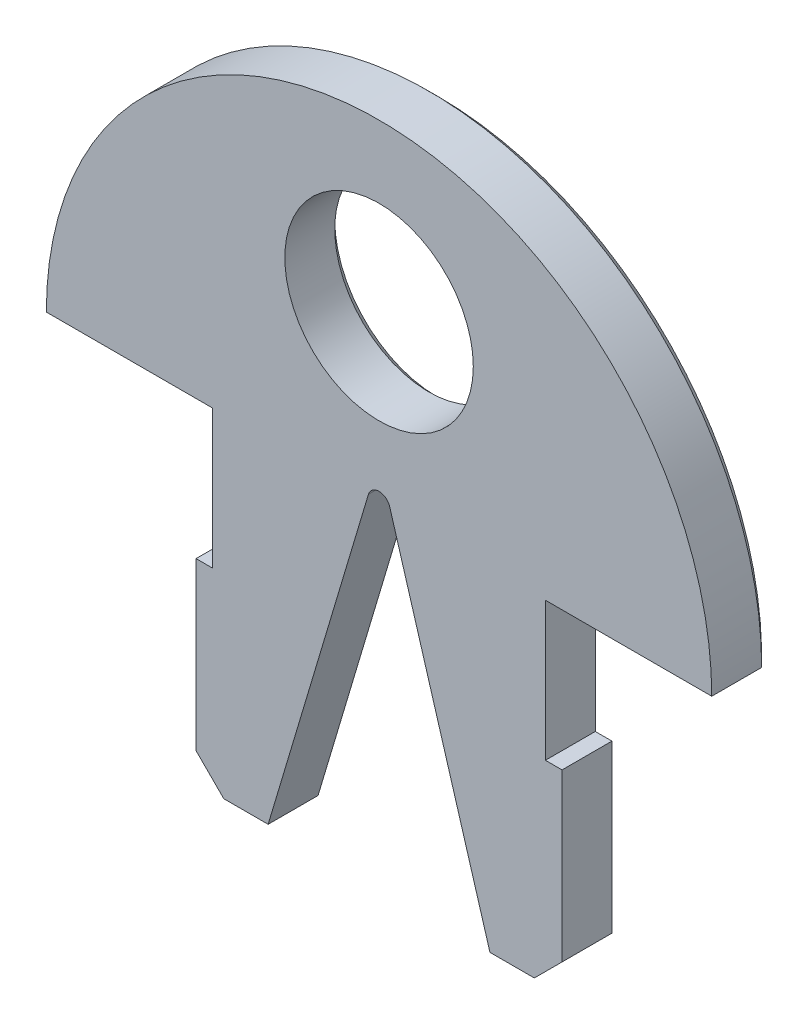
from build123d import *

# Parameters (mm, degrees)
SKETCH1_R           = 3.399254874
BOSS_EXTRUDE1_DEPTH = 2.1
CHAMFER1_SIZE       = 1
CHAMFER2_SIZE       = 0.3


with BuildPart() as part:
    # Sketch1 → Boss-Extrude1 (new body)
    with BuildSketch(Plane.XY):
        with BuildLine():
            Line((6, 6), (12, 6))
            ThreePointArc((12, 6), (0, 18), (-12, 6))
            Line((-12, 6), (-6, 6))
            Line((-6, 6), (-6, 1))
            Line((-6, 1), (-6.6, 1))
            Line((-6.6, 1), (-6.6, -6))
            Line((-6.6, -6), (-6, -6))
            Line((-6, -6), (-4, -6))
            Line((-4, -6), (-0.383283535, 6.114427845))
            ThreePointArc((-0.383283535, 6.114427845), (0, 6.4), (0.383283535, 6.114427845))
            Line((0.383283535, 6.114427845), (4, -6))
            Line((4, -6), (6, -6))
            Line((6, -6), (6.6, -6))
            Line((6.6, -6), (6.6, 1))
            Line((6.6, 1), (6, 1))
            Line((6, 1), (6, 6))
        make_face()
        with Locations((0, 12)):
            Circle(SKETCH1_R, mode=Mode.SUBTRACT)
    extrude(amount=BOSS_EXTRUDE1_DEPTH)

    # Chamfer1
    chamfer1_edges = [part.edges().sort_by_distance(p)[0] for p in [
        (-6.6, -6, 1.05),
        (6.6, -6, 1.05),
    ]]
    chamfer(chamfer1_edges, length=CHAMFER1_SIZE)

    # Chamfer2
    chamfer2_edges = [part.edges().sort_by_distance(p)[0] for p in [
        (2.191641768, 0.057213923, 0),
        (0, 6.4, 0),
        (-2.191641768, 0.057213923, 0),
        (-6.6, -2, 0),
        (-6.3, 1, 0),
        (-6, 3.5, 0),
        (-9, 6, 0),
        (0, 18, 0),
        (9, 6, 0),
        (6, 3.5, 0),
        (6.3, 1, 0),
        (4.8, -6, 0),
        (-3.399254874, 12, 0),
        (6.6, -2, 0),
        (-4.8, -6, 0),
        (-6.1, -5.5, 0),
        (6.1, -5.5, 0),
    ]]
    chamfer(chamfer2_edges, length=CHAMFER2_SIZE)


solid = part.part
